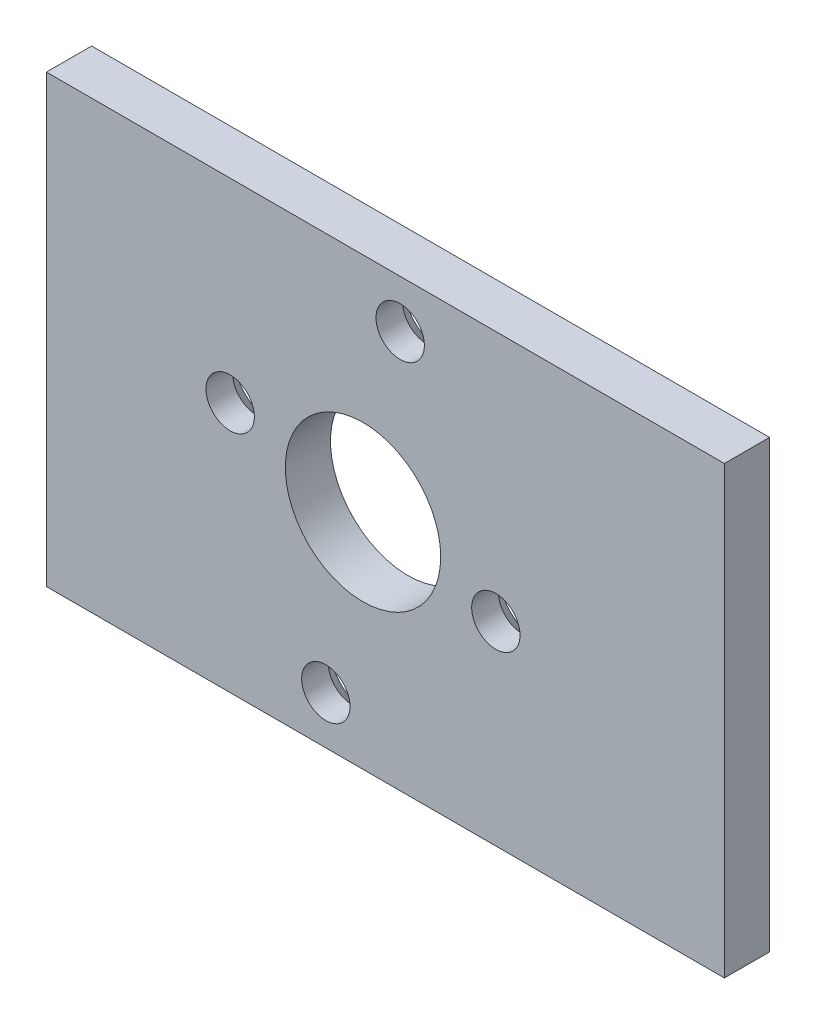
from build123d import *

# Parameters (mm, degrees)
SKETCH1_W           = 47.6504
SKETCH1_H           = 31.3182
SKETCH1_R           = 1.7
SKETCH1_R_2         = 5.461
BOSS_EXTRUDE1_DEPTH = 3.175
CHAMFER1_SIZE       = 1.29999994


with BuildPart() as part:
    # Sketch1 → Boss-Extrude1 (new body)
    with BuildSketch(Plane.XY):
        with Locations((1.5748, 0)):
            Rectangle(SKETCH1_W, SKETCH1_H)
        with Locations((9.336418849, -1.984517089)):
            Circle(SKETCH1_R, mode=Mode.SUBTRACT)
        with Locations((-9.336418849, 1.984517089)):
            Circle(SKETCH1_R, mode=Mode.SUBTRACT)
        with Locations((2.613449954, 12.295315341)):
            Circle(SKETCH1_R, mode=Mode.SUBTRACT)
        with Locations((-2.613449954, -12.295315341)):
            Circle(SKETCH1_R, mode=Mode.SUBTRACT)
        Circle(SKETCH1_R_2, mode=Mode.SUBTRACT)
    extrude(amount=BOSS_EXTRUDE1_DEPTH)

    # Chamfer1
    chamfer1_edges = [part.edges().sort_by_distance(p)[0] for p in [
        (7.636418849, -1.984517089, 0),
        (-11.036418849, 1.984517089, 0),
        (0.913449954, 12.295315341, 0),
        (-4.313449954, -12.295315341, 0),
    ]]
    chamfer(chamfer1_edges, length=CHAMFER1_SIZE)


solid = part.part
